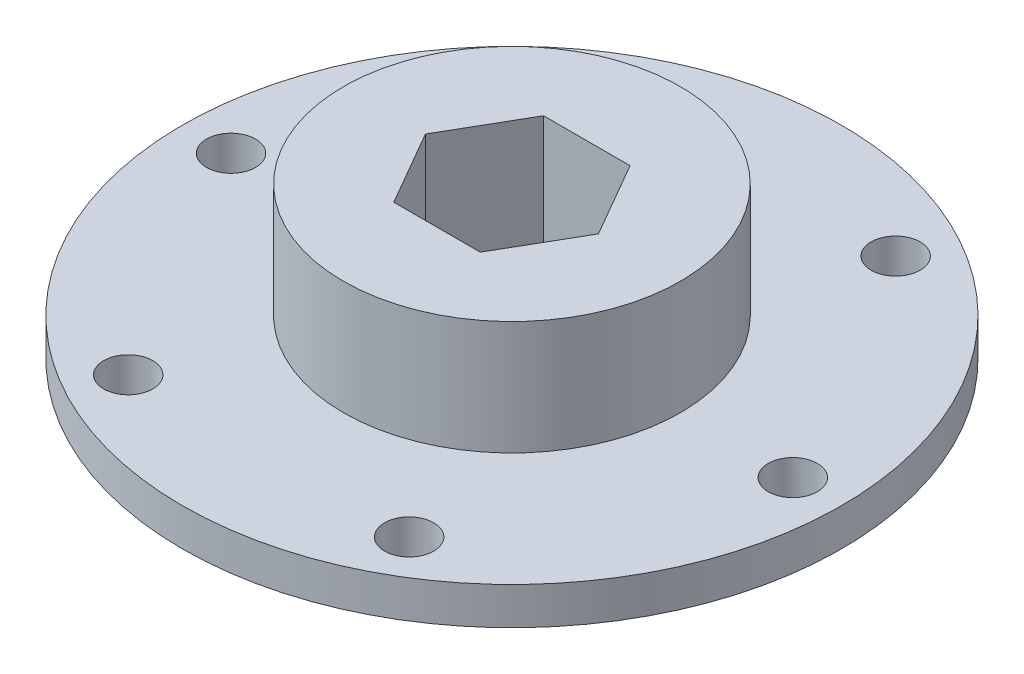
from build123d import *

# Parameters (mm, degrees)
SKETCH1_R           = 27.94
BOSS_EXTRUDE1_DEPTH = 3.175
SKETCH2_R           = 14.2875
BOSS_EXTRUDE2_DEPTH = 9.652
CUT_EXTRUDE1_DEPTH  = 13.827
SKETCH4_R           = 2.0828
CUT_EXTRUDE2_DEPTH  = 13.827


with BuildPart() as part:
    # Sketch1 → Boss-Extrude1 (new body)
    with BuildSketch(Plane(origin=(0, 0, 0), x_dir=(1, 0, 0), z_dir=(0, 1, 0))):
        Circle(SKETCH1_R)
    extrude(amount=BOSS_EXTRUDE1_DEPTH)

    # Sketch2 → Boss-Extrude2 (add)
    with BuildSketch(Plane(origin=(0, 3.175, 0), x_dir=(1, 0, 0), z_dir=(0, 1, 0))):
        Circle(SKETCH2_R)
    extrude(amount=BOSS_EXTRUDE2_DEPTH)

    # Sketch3 → Cut-Extrude1 (cut, through all)
    with BuildSketch(Plane.XZ):
        Polygon((3.666174209, -6.35), (7.332348419, 0), (3.666174209, 6.35), (-3.666174209, 6.35), (-7.332348419, 0), (-3.666174209, -6.35), align=None)
    extrude(amount=-CUT_EXTRUDE1_DEPTH, mode=Mode.SUBTRACT)

    # Sketch4 → Cut-Extrude2 (cut, through all)
    with BuildSketch(Plane.XZ):
        with Locations((-11.90625, 20.622229928)):
            Circle(SKETCH4_R)
        with Locations((11.90625, 20.622229928)):
            Circle(SKETCH4_R)
        with Locations((23.8125, 0)):
            Circle(SKETCH4_R)
        with Locations((11.90625, -20.622229928)):
            Circle(SKETCH4_R)
        with Locations((-11.90625, -20.622229928)):
            Circle(SKETCH4_R)
        with Locations((-23.8125, 0)):
            Circle(SKETCH4_R)
    extrude(amount=-CUT_EXTRUDE2_DEPTH, mode=Mode.SUBTRACT)


solid = part.part
